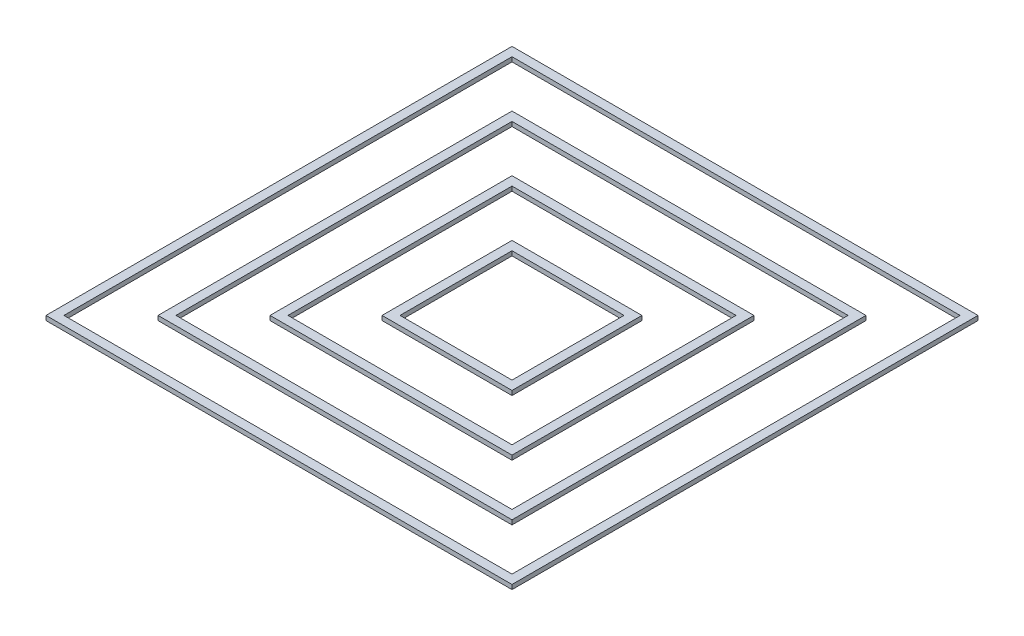
from build123d import *

# Parameters (mm, degrees)
SKETCH1_W             = 208
SKETCH1_H             = 208
SKETCH1_W_2           = 200
SKETCH1_H_2           = 200
EXTRUDE_THIN1_DEPTH   = 2
SKETCH1_W_3           = 158
SKETCH1_H_3           = 158
SKETCH1_W_4           = 150
SKETCH1_H_4           = 150
EXTRUDE_THIN1_2_DEPTH = 2
SKETCH1_W_5           = 108
SKETCH1_H_5           = 108
SKETCH1_W_6           = 100
SKETCH1_H_6           = 100
EXTRUDE_THIN1_3_DEPTH = 2
SKETCH1_W_7           = 58
SKETCH1_H_7           = 58
SKETCH1_W_8           = 50
SKETCH1_H_8           = 50
EXTRUDE_THIN1_4_DEPTH = 2


with BuildPart() as part:
    # Sketch1 → Extrude-Thin1 (new body)
    with BuildSketch(Plane(origin=(0, 0, 0), x_dir=(1, 0, 0), z_dir=(0, 1, 0))):
        with Locations((14.132379249, -40.429338104)):
            Rectangle(SKETCH1_W, SKETCH1_H)
        with Locations((14.132379249, -40.429338104)):
            Rectangle(SKETCH1_W_2, SKETCH1_H_2, mode=Mode.SUBTRACT)
    extrude(amount=EXTRUDE_THIN1_DEPTH)


with BuildPart() as body_2:
    # Sketch1 → Extrude-Thin1 2 (new body)
    with BuildSketch(Plane(origin=(0, 0, 0), x_dir=(1, 0, 0), z_dir=(0, 1, 0))):
        with Locations((14.132379249, -40.429338104)):
            Rectangle(SKETCH1_W_3, SKETCH1_H_3)
        with Locations((14.132379249, -40.429338104)):
            Rectangle(SKETCH1_W_4, SKETCH1_H_4, mode=Mode.SUBTRACT)
    extrude(amount=EXTRUDE_THIN1_2_DEPTH)


with BuildPart() as body_3:
    # Sketch1 → Extrude-Thin1 3 (new body)
    with BuildSketch(Plane(origin=(0, 0, 0), x_dir=(1, 0, 0), z_dir=(0, 1, 0))):
        with Locations((14.132379249, -40.429338104)):
            Rectangle(SKETCH1_W_5, SKETCH1_H_5)
        with Locations((14.132379249, -40.429338104)):
            Rectangle(SKETCH1_W_6, SKETCH1_H_6, mode=Mode.SUBTRACT)
    extrude(amount=EXTRUDE_THIN1_3_DEPTH)


with BuildPart() as body_4:
    # Sketch1 → Extrude-Thin1 4 (new body)
    with BuildSketch(Plane(origin=(0, 0, 0), x_dir=(1, 0, 0), z_dir=(0, 1, 0))):
        with Locations((14.132379249, -40.429338104)):
            Rectangle(SKETCH1_W_7, SKETCH1_H_7)
        with Locations((14.132379249, -40.429338104)):
            Rectangle(SKETCH1_W_8, SKETCH1_H_8, mode=Mode.SUBTRACT)
    extrude(amount=EXTRUDE_THIN1_4_DEPTH)


solid = Compound([part.part, body_2.part, body_3.part, body_4.part])
